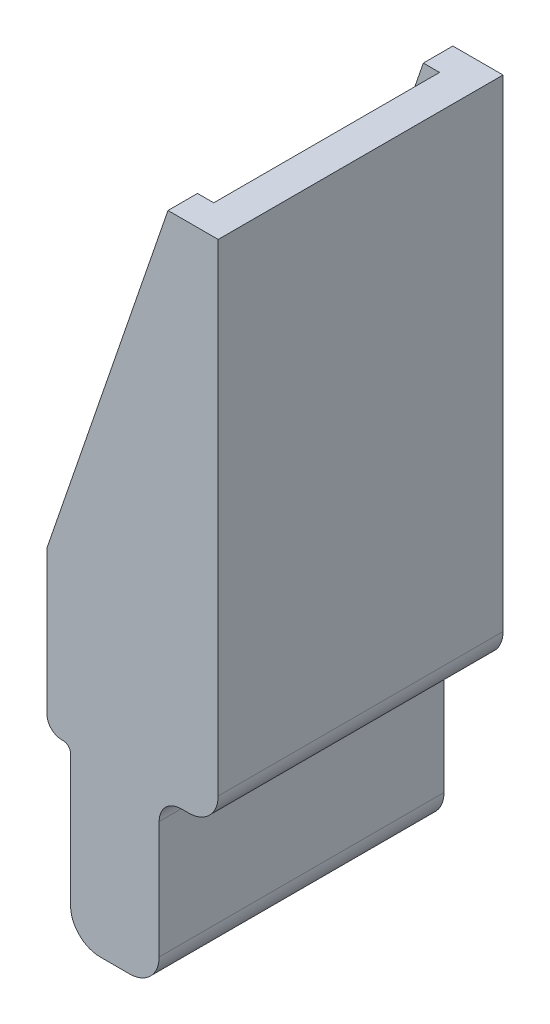
from build123d import *

# Parameters (mm, degrees)
SALIENTE_EXTRUIR1_DEPTH = 19.3
CROQUIS2_W              = 15.3
CROQUIS2_H              = 26.3
CORTAR_EXTRUIR1_DEPTH   = 9.3


with BuildPart() as part:
    # Croquis1 → Saliente-Extruir1 (new body)
    with BuildSketch(Plane.XY):
        with BuildLine():
            Line((5.8, 23.05), (2.4, 23.05))
            Line((2.4, 23.05), (-5.8, -0.85))
            Line((-5.8, -0.85), (-5.8, -10.609737321))
            ThreePointArc((-5.8, -10.609737321), (-5.505459406, -11.318487649), (-4.795345946, -11.609726491))
            Line((-4.795345946, -11.609726491), (-4.702327027, -11.609293571))
            ThreePointArc((-4.702327027, -11.609293571), (-4.347270297, -11.754912992), (-4.2, -12.109288156))
            Line((-4.2, -12.109288156), (-4.2, -21.05))
            ThreePointArc((-4.2, -21.05), (-3.614213562, -22.464213562), (-2.2, -23.05))
            Line((-2.2, -23.05), (-0.2, -23.05))
            ThreePointArc((-0.2, -23.05), (1.214213562, -22.464213562), (1.8, -21.05))
            Line((1.8, -21.05), (1.8, -13.106955688))
            ThreePointArc((1.8, -13.106955688), (2.239339828, -12.046295517), (3.3, -11.606955688))
            Line((3.3, -11.606955688), (3.8, -11.606955688))
            ThreePointArc((3.8, -11.606955688), (5.214213562, -11.021169251), (5.8, -9.606955688))
            Line((5.8, -9.606955688), (5.8, 23.05))
        make_face()
    extrude(amount=SALIENTE_EXTRUIR1_DEPTH)

    # Croquis2 → Cortar-Extruir1 (cut)
    with BuildSketch(Plane.ZY.offset(5.8)):
        with Locations((9.65, 9.9)):
            Rectangle(CROQUIS2_W, CROQUIS2_H)
    extrude(amount=-CORTAR_EXTRUIR1_DEPTH, mode=Mode.SUBTRACT)


solid = part.part
